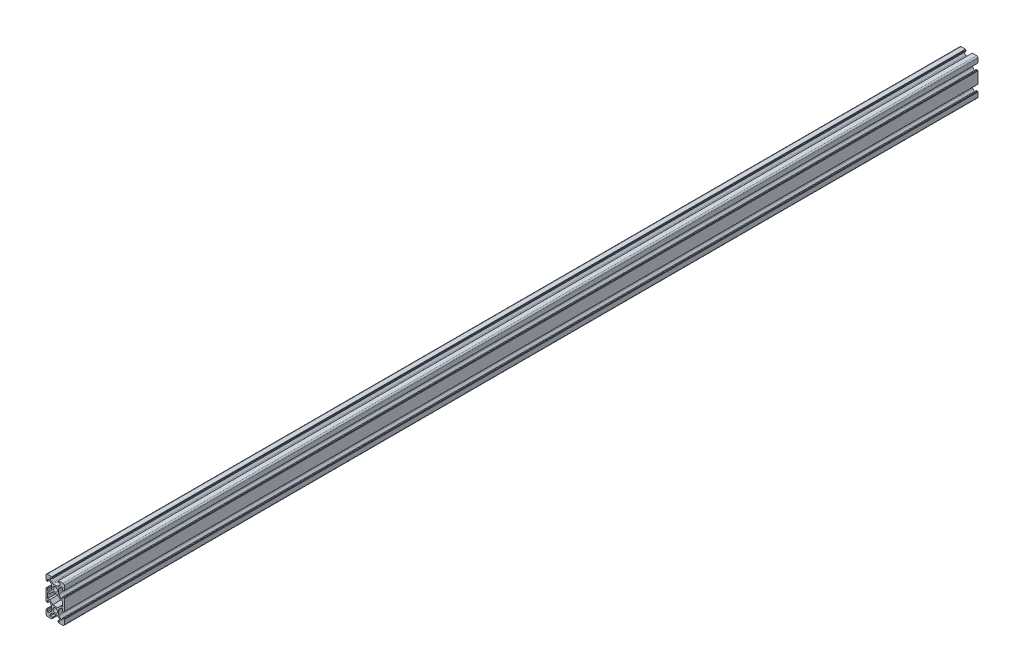
from build123d import *

# Parameters (mm, degrees)
SKETCH_3_R      = 2.5
EXTRUDE_1_DEPTH = 1000


with BuildPart() as part:
    # Эскиз3 → Бобышка-Вытянуть1 (new body)
    with BuildSketch(Plane.XY):
        with BuildLine():
            Line((-10, 5.5), (-10, 8.5))
            ThreePointArc((-10, 8.5), (-9.560660172, 9.560660172), (-8.5, 10))
            Line((-8.5, 10), (-5.5, 10))
            Line((-5.5, 10), (-3.75, 10))
            ThreePointArc((-3.75, 10), (-3.643933983, 9.956066017), (-3.6, 9.85))
            Line((-3.6, 9.85), (-3.6, 9.65))
            ThreePointArc((-3.6, 9.65), (-3.556066017, 9.543933983), (-3.45, 9.5))
            Line((-3.45, 9.5), (-3.25, 9.5))
            ThreePointArc((-3.25, 9.5), (-3.143933983, 9.456066017), (-3.1, 9.35))
            Line((-3.1, 9.35), (-3.1, 8.35))
            ThreePointArc((-3.1, 8.35), (-3.143933983, 8.243933983), (-3.25, 8.2))
            Line((-3.25, 8.2), (-5.5, 8.2))
            Line((-5.5, 8.2), (-5.5, 6.6))
            Line((-5.5, 6.6), (-3.239339828, 4.339339828))
            ThreePointArc((-3.239339828, 4.339339828), (-2.752704805, 4.014180701), (-2.178679656, 3.9))
            Line((-2.178679656, 3.9), (2.178679656, 3.9))
            ThreePointArc((2.178679656, 3.9), (2.752704805, 4.014180701), (3.239339828, 4.339339828))
            Line((3.239339828, 4.339339828), (5.5, 6.6))
            Line((5.5, 6.6), (5.5, 8.2))
            Line((5.5, 8.2), (3.25, 8.2))
            ThreePointArc((3.25, 8.2), (3.143933983, 8.243933983), (3.1, 8.35))
            Line((3.1, 8.35), (3.1, 9.35))
            ThreePointArc((3.1, 9.35), (3.143933983, 9.456066017), (3.25, 9.5))
            Line((3.25, 9.5), (3.45, 9.5))
            ThreePointArc((3.45, 9.5), (3.556066017, 9.543933983), (3.6, 9.65))
            Line((3.6, 9.65), (3.6, 9.85))
            ThreePointArc((3.6, 9.85), (3.643933983, 9.956066017), (3.75, 10))
            Line((3.75, 10), (5.5, 10))
            Line((5.5, 10), (8.5, 10))
            ThreePointArc((8.5, 10), (9.560660172, 9.560660172), (10, 8.5))
            Line((10, 8.5), (10, 5.5))
            Line((10, 5.5), (10, 3.75))
            ThreePointArc((10, 3.75), (9.956066017, 3.643933983), (9.85, 3.6))
            Line((9.85, 3.6), (9.65, 3.6))
            ThreePointArc((9.65, 3.6), (9.543933983, 3.556066017), (9.5, 3.45))
            Line((9.5, 3.45), (9.5, 3.25))
            ThreePointArc((9.5, 3.25), (9.456066017, 3.143933983), (9.35, 3.1))
            Line((9.35, 3.1), (8.35, 3.1))
            ThreePointArc((8.35, 3.1), (8.243933983, 3.143933983), (8.2, 3.25))
            Line((8.2, 3.25), (8.2, 5.5))
            Line((8.2, 5.5), (6.6, 5.5))
            Line((6.6, 5.5), (4.339339828, 3.239339828))
            ThreePointArc((4.339339828, 3.239339828), (4.014180701, 2.752704805), (3.9, 2.178679656))
            Line((3.9, 2.178679656), (3.9, -2.178679656))
            ThreePointArc((3.9, -2.178679656), (4.014180701, -2.752704805), (4.339339828, -3.239339828))
            Line((4.339339828, -3.239339828), (6.6, -5.5))
            Line((6.6, -5.5), (8.2, -5.5))
            Line((8.2, -5.5), (8.2, -3.25))
            ThreePointArc((8.2, -3.25), (8.243933983, -3.143933983), (8.35, -3.1))
            Line((8.35, -3.1), (9.35, -3.1))
            ThreePointArc((9.35, -3.1), (9.456066017, -3.143933983), (9.5, -3.25))
            Line((9.5, -3.25), (9.5, -3.45))
            ThreePointArc((9.5, -3.45), (9.543933983, -3.556066017), (9.65, -3.6))
            Line((9.65, -3.6), (9.85, -3.6))
            ThreePointArc((9.85, -3.6), (9.956066017, -3.643933983), (10, -3.75))
            Line((10, -3.75), (10, -5.5))
            Line((10, -5.5), (10, -14.5))
            Line((10, -14.5), (10, -16.25))
            ThreePointArc((10, -16.25), (9.956066017, -16.356066017), (9.85, -16.4))
            Line((9.85, -16.4), (9.65, -16.4))
            ThreePointArc((9.65, -16.4), (9.543933983, -16.443933983), (9.5, -16.55))
            Line((9.5, -16.55), (9.5, -16.75))
            ThreePointArc((9.5, -16.75), (9.456066017, -16.856066017), (9.35, -16.9))
            Line((9.35, -16.9), (8.35, -16.9))
            ThreePointArc((8.35, -16.9), (8.243933983, -16.856066017), (8.2, -16.75))
            Line((8.2, -16.75), (8.2, -14.5))
            Line((8.2, -14.5), (6.6, -14.5))
            Line((6.6, -14.5), (4.339339828, -16.760660172))
            ThreePointArc((4.339339828, -16.760660172), (4.014180701, -17.247295195), (3.9, -17.821320344))
            Line((3.9, -17.821320344), (3.9, -22.178679656))
            ThreePointArc((3.9, -22.178679656), (4.014180701, -22.752704805), (4.339339828, -23.239339828))
            Line((4.339339828, -23.239339828), (6.6, -25.5))
            Line((6.6, -25.5), (8.2, -25.5))
            Line((8.2, -25.5), (8.2, -23.25))
            ThreePointArc((8.2, -23.25), (8.243933983, -23.143933983), (8.35, -23.1))
            Line((8.35, -23.1), (9.35, -23.1))
            ThreePointArc((9.35, -23.1), (9.456066017, -23.143933983), (9.5, -23.25))
            Line((9.5, -23.25), (9.5, -23.45))
            ThreePointArc((9.5, -23.45), (9.543933983, -23.556066017), (9.65, -23.6))
            Line((9.65, -23.6), (9.85, -23.6))
            ThreePointArc((9.85, -23.6), (9.956066017, -23.643933983), (10, -23.75))
            Line((10, -23.75), (10, -25.5))
            Line((10, -25.5), (10, -28.5))
            ThreePointArc((10, -28.5), (9.560660172, -29.560660172), (8.5, -30))
            Line((8.5, -30), (5.5, -30))
            Line((5.5, -30), (3.75, -30))
            ThreePointArc((3.75, -30), (3.643933983, -29.956066017), (3.6, -29.85))
            Line((3.6, -29.85), (3.6, -29.65))
            ThreePointArc((3.6, -29.65), (3.556066017, -29.543933983), (3.45, -29.5))
            Line((3.45, -29.5), (3.25, -29.5))
            ThreePointArc((3.25, -29.5), (3.143933983, -29.456066017), (3.1, -29.35))
            Line((3.1, -29.35), (3.1, -28.35))
            ThreePointArc((3.1, -28.35), (3.143933983, -28.243933983), (3.25, -28.2))
            Line((3.25, -28.2), (5.5, -28.2))
            Line((5.5, -28.2), (5.5, -26.6))
            Line((5.5, -26.6), (3.239339828, -24.339339828))
            ThreePointArc((3.239339828, -24.339339828), (2.752704805, -24.014180701), (2.178679656, -23.9))
            Line((2.178679656, -23.9), (-2.178679656, -23.9))
            ThreePointArc((-2.178679656, -23.9), (-2.752704805, -24.014180701), (-3.239339828, -24.339339828))
            Line((-3.239339828, -24.339339828), (-5.5, -26.6))
            Line((-5.5, -26.6), (-5.5, -28.2))
            Line((-5.5, -28.2), (-3.25, -28.2))
            ThreePointArc((-3.25, -28.2), (-3.143933983, -28.243933983), (-3.1, -28.35))
            Line((-3.1, -28.35), (-3.1, -29.35))
            ThreePointArc((-3.1, -29.35), (-3.143933983, -29.456066017), (-3.25, -29.5))
            Line((-3.25, -29.5), (-3.45, -29.5))
            ThreePointArc((-3.45, -29.5), (-3.556066017, -29.543933983), (-3.6, -29.65))
            Line((-3.6, -29.65), (-3.6, -29.85))
            ThreePointArc((-3.6, -29.85), (-3.643933983, -29.956066017), (-3.75, -30))
            Line((-3.75, -30), (-5.5, -30))
            Line((-5.5, -30), (-8.5, -30))
            ThreePointArc((-8.5, -30), (-9.560660172, -29.560660172), (-10, -28.5))
            Line((-10, -28.5), (-10, -25.5))
            Line((-10, -25.5), (-10, -23.75))
            ThreePointArc((-10, -23.75), (-9.956066017, -23.643933983), (-9.85, -23.6))
            Line((-9.85, -23.6), (-9.65, -23.6))
            ThreePointArc((-9.65, -23.6), (-9.543933983, -23.556066017), (-9.5, -23.45))
            Line((-9.5, -23.45), (-9.5, -23.25))
            ThreePointArc((-9.5, -23.25), (-9.456066017, -23.143933983), (-9.35, -23.1))
            Line((-9.35, -23.1), (-8.35, -23.1))
            ThreePointArc((-8.35, -23.1), (-8.243933983, -23.143933983), (-8.2, -23.25))
            Line((-8.2, -23.25), (-8.2, -25.5))
            Line((-8.2, -25.5), (-6.6, -25.5))
            Line((-6.6, -25.5), (-4.339339828, -23.239339828))
            ThreePointArc((-4.339339828, -23.239339828), (-4.014180701, -22.752704805), (-3.9, -22.178679656))
            Line((-3.9, -22.178679656), (-3.9, -17.821320344))
            ThreePointArc((-3.9, -17.821320344), (-4.014180701, -17.247295195), (-4.339339828, -16.760660172))
            Line((-4.339339828, -16.760660172), (-6.6, -14.5))
            Line((-6.6, -14.5), (-8.2, -14.5))
            Line((-8.2, -14.5), (-8.2, -16.75))
            ThreePointArc((-8.2, -16.75), (-8.243933983, -16.856066017), (-8.35, -16.9))
            Line((-8.35, -16.9), (-9.35, -16.9))
            ThreePointArc((-9.35, -16.9), (-9.456066017, -16.856066017), (-9.5, -16.75))
            Line((-9.5, -16.75), (-9.5, -16.55))
            ThreePointArc((-9.5, -16.55), (-9.543933983, -16.443933983), (-9.65, -16.4))
            Line((-9.65, -16.4), (-9.85, -16.4))
            ThreePointArc((-9.85, -16.4), (-9.956066017, -16.356066017), (-10, -16.25))
            Line((-10, -16.25), (-10, -14.5))
            Line((-10, -14.5), (-10, -5.5))
            Line((-10, -5.5), (-10, -3.75))
            ThreePointArc((-10, -3.75), (-9.956066017, -3.643933983), (-9.85, -3.6))
            Line((-9.85, -3.6), (-9.65, -3.6))
            ThreePointArc((-9.65, -3.6), (-9.543933983, -3.556066017), (-9.5, -3.45))
            Line((-9.5, -3.45), (-9.5, -3.25))
            ThreePointArc((-9.5, -3.25), (-9.456066017, -3.143933983), (-9.35, -3.1))
            Line((-9.35, -3.1), (-8.35, -3.1))
            ThreePointArc((-8.35, -3.1), (-8.243933983, -3.143933983), (-8.2, -3.25))
            Line((-8.2, -3.25), (-8.2, -5.5))
            Line((-8.2, -5.5), (-6.6, -5.5))
            Line((-6.6, -5.5), (-4.339339828, -3.239339828))
            ThreePointArc((-4.339339828, -3.239339828), (-4.014180701, -2.752704805), (-3.9, -2.178679656))
            Line((-3.9, -2.178679656), (-3.9, 2.178679656))
            ThreePointArc((-3.9, 2.178679656), (-4.014180701, 2.752704805), (-4.339339828, 3.239339828))
            Line((-4.339339828, 3.239339828), (-6.6, 5.5))
            Line((-6.6, 5.5), (-8.2, 5.5))
            Line((-8.2, 5.5), (-8.2, 3.25))
            ThreePointArc((-8.2, 3.25), (-8.243933983, 3.143933983), (-8.35, 3.1))
            Line((-8.35, 3.1), (-9.35, 3.1))
            ThreePointArc((-9.35, 3.1), (-9.456066017, 3.143933983), (-9.5, 3.25))
            Line((-9.5, 3.25), (-9.5, 3.45))
            ThreePointArc((-9.5, 3.45), (-9.543933983, 3.556066017), (-9.65, 3.6))
            Line((-9.65, 3.6), (-9.85, 3.6))
            ThreePointArc((-9.85, 3.6), (-9.956066017, 3.643933983), (-10, 3.75))
            Line((-10, 3.75), (-10, 5.5))
        make_face()
        Circle(SKETCH_3_R, mode=Mode.SUBTRACT)
        with Locations((0, -20)):
            Circle(SKETCH_3_R, mode=Mode.SUBTRACT)
        Polygon((8.2, -7.1), (8.2, -12.9), (5.9372583, -12.9), (2.7372583, -16.1), (-2.7372583, -16.1), (-5.9372583, -12.9), (-8.2, -12.9), (-8.2, -7.1), (-5.9372583, -7.1), (-2.7372583, -3.9), (2.7372583, -3.9), (5.9372583, -7.1), align=None, mode=Mode.SUBTRACT)
    extrude(amount=EXTRUDE_1_DEPTH)


solid = part.part
